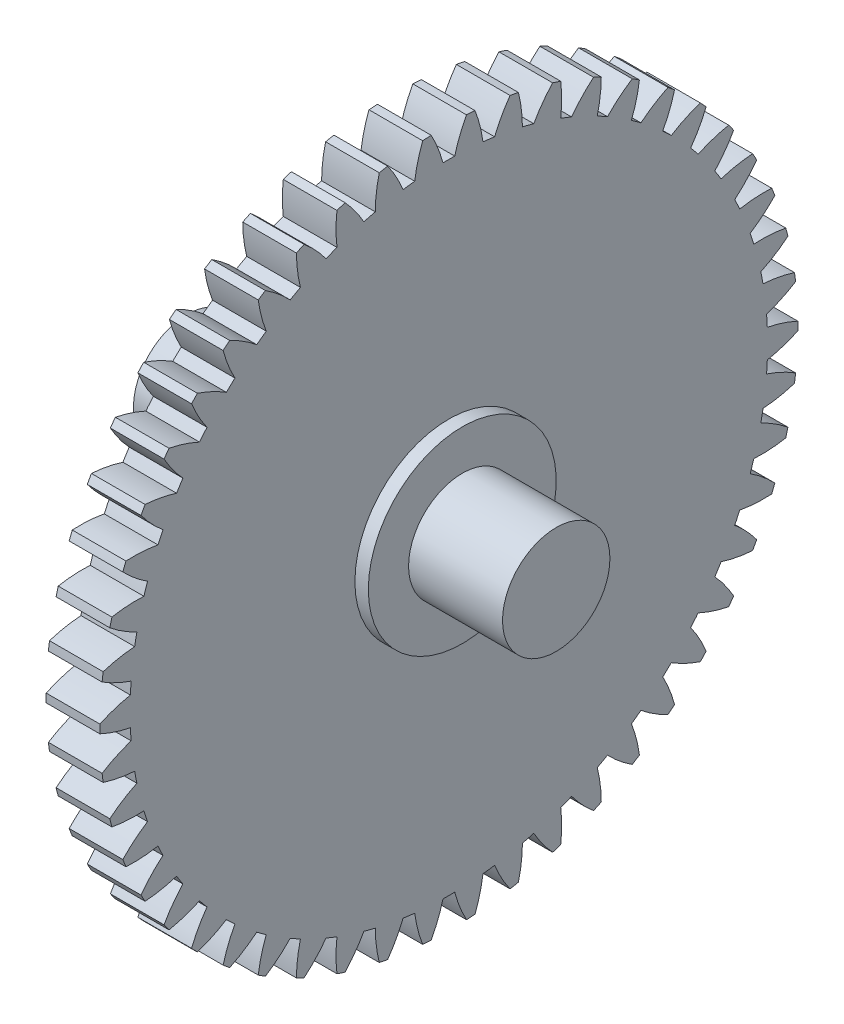
from build123d import *

# Parameters (mm, degrees)
BASPROSKE_W              = 4
BASPROSKE_H              = 26
TOOTHCUT_DEPTH           = 37.986484018
TEETHCUTS_COUNT          = 50
TEETHCUTS_ANGLE          = 352.8
BORSKE_R                 = 7
BOSS_EXTRUDE1_DEPTH      = 5
BOSS_EXTRUDE1_DEPTH_BACK = 8.5
SKETCH1_R                = 4
BOSS_EXTRUDE2_DEPTH      = 7
BOSS_EXTRUDE2_DEPTH_BACK = 20.5


with BuildPart() as part:
    # BasProSke → Base-Revolve (revolve)
    with BuildSketch(Plane(origin=(0, 0, 0), x_dir=(1, 0, 0), z_dir=(0, 1, 0)), mode=Mode.PRIVATE) as base_revolve_sk:
        with Locations((2, 13)):
            Rectangle(BASPROSKE_W, BASPROSKE_H)
    revolve(base_revolve_sk.sketch.rotate(Axis((-10, 0, 0), (1, 0, 0)), 180), axis=Axis((-10, 0, 0), (1, 0, 0)))

    # TooCutSke → ToothCut (cut, through all)
    with BuildSketch(Plane(origin=(0, 0, 0), x_dir=(0, 0, -1), z_dir=(1, 0, 0))):
        with BuildLine():
            ThreePointArc((0.437663408, 23.744966872), (0, 23.749), (-0.437663408, 23.744966872))
            ThreePointArc((-0.437663408, 23.744966872), (-0.815428123, 24.895236298), (-1.329433358, 25.991422664))
            ThreePointArc((-1.329433358, 25.991422664), (0, 26.0254), (1.329433358, 25.991422664))
            ThreePointArc((1.329433358, 25.991422664), (0.815428123, 24.895236298), (0.437663408, 23.744966872))
        make_face()
    toothcut = extrude(amount=TOOTHCUT_DEPTH, mode=Mode.SUBTRACT)

    # TeethCuts: ToothCut ×50 about axis
    teethcuts_axis = Axis((-10, 0, 0), (1, 0, 0))
    for i in range(1, TEETHCUTS_COUNT):
        add(toothcut.rotate(teethcuts_axis, i * TEETHCUTS_ANGLE / (TEETHCUTS_COUNT - 1)), mode=Mode.SUBTRACT)

    # BorSke → Boss-Extrude1 (add, two sides)
    with BuildSketch(Plane(origin=(0, 0, 0), x_dir=(0, 0, -1), z_dir=(1, 0, 0))) as boss_extrude1_sk:
        with Locations(Location((0, 0, 0), (0, 0, 180))):
            Circle(BORSKE_R)
    extrude(amount=BOSS_EXTRUDE1_DEPTH)
    extrude(boss_extrude1_sk.sketch, amount=-BOSS_EXTRUDE1_DEPTH_BACK)

    # Sketch1 → Boss-Extrude2 (add, two sides)
    with BuildSketch(Plane(origin=(5, 0, 0), x_dir=(0, 0, -1), z_dir=(1, 0, 0))) as boss_extrude2_sk:
        with Locations(Location((0, 0, 0), (0, 0, 180))):
            Circle(SKETCH1_R)
    extrude(amount=BOSS_EXTRUDE2_DEPTH)
    extrude(boss_extrude2_sk.sketch, amount=-BOSS_EXTRUDE2_DEPTH_BACK)


solid = part.part
